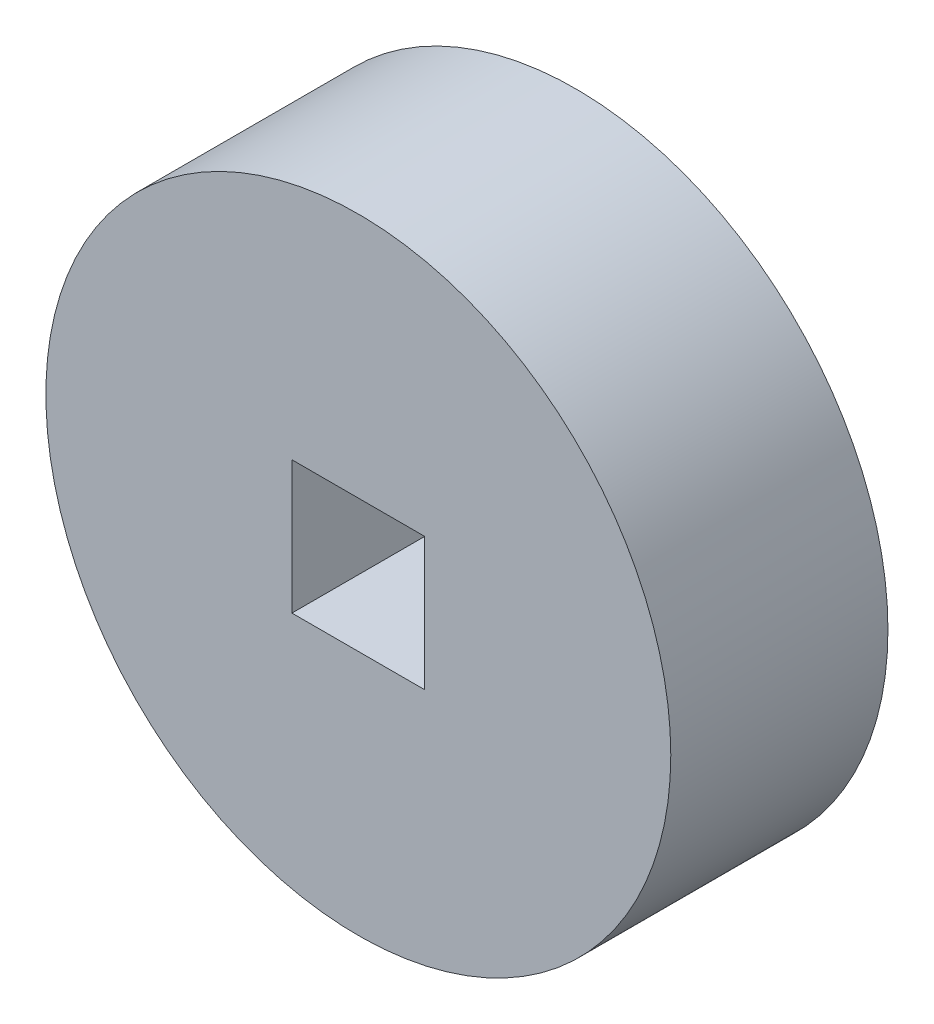
from build123d import *

# Parameters (mm, degrees)
BOSS_EXTRUDE1_START = 8
SKETCH1_R           = 12
BOSS_EXTRUDE1_DEPTH = 8.34
SKETCH3_W           = 5.1
SKETCH3_H           = 5.1
CUT_EXTRUDE4_DEPTH  = 9


with BuildPart() as part:
    # Sketch1 → Boss-Extrude1 (new body)
    with BuildSketch(Plane.XY.offset(BOSS_EXTRUDE1_START)):
        Circle(SKETCH1_R)
    extrude(amount=-BOSS_EXTRUDE1_DEPTH)

    # Sketch3 → Cut-Extrude4 (cut, through all)
    with BuildSketch(Plane.XY):
        Rectangle(SKETCH3_W, SKETCH3_H)
    extrude(amount=CUT_EXTRUDE4_DEPTH, mode=Mode.SUBTRACT)


solid = part.part
